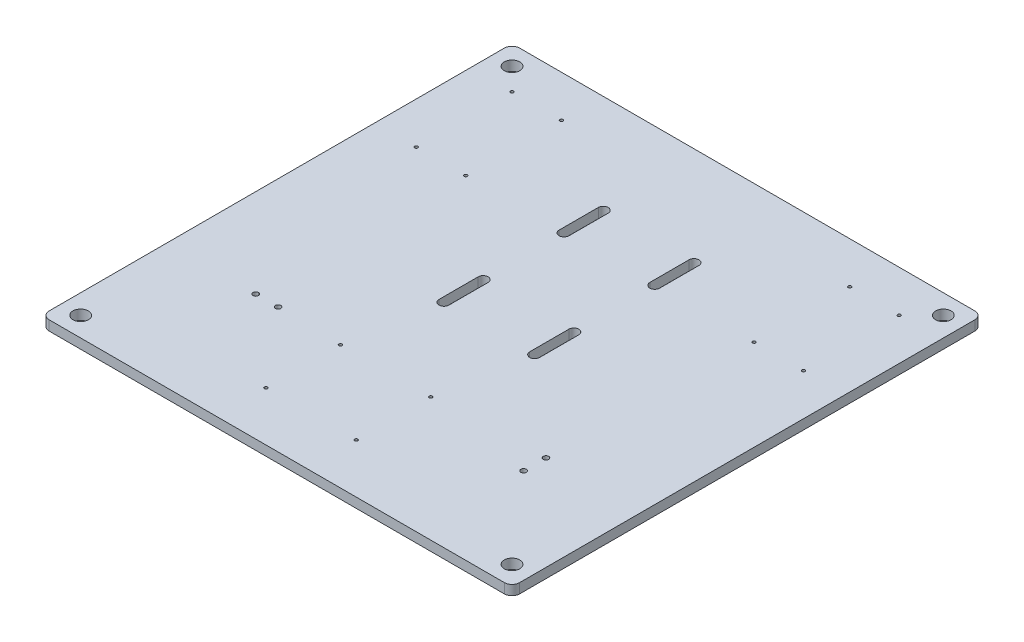
from build123d import *

# Parameters (mm, degrees)
SKETCH2_W           = 304.8
SKETCH2_H           = 304.8
SKETCH2_R           = 1
SKETCH2_R_2         = 1.75
SKETCH2_R_3         = 5
SKETCH2_R_4         = 1.016
BOSS_EXTRUDE1_DEPTH = 6.35
FILLET1_R           = 5
FILLET2_R           = 5
FILLET3_R           = 5
FILLET4_R           = 5


with BuildPart() as part:
    # Sketch2 → Boss-Extrude1 (new body)
    with BuildSketch(Plane(origin=(0, 0, 0), x_dir=(1, 0, 0), z_dir=(0, 1, 0))):
        with Locations((24.008323043, 69.071116712)):
            Rectangle(SKETCH2_W, SKETCH2_H)
        with Locations((-101.391676957, 132.471116712)):
            Circle(SKETCH2_R, mode=Mode.SUBTRACT)
        with Locations((-69.391676957, 132.471116712)):
            Circle(SKETCH2_R, mode=Mode.SUBTRACT)
        with Locations((-101.391676957, 194.471116712)):
            Circle(SKETCH2_R, mode=Mode.SUBTRACT)
        with Locations((-69.391676957, 194.471116712)):
            Circle(SKETCH2_R, mode=Mode.SUBTRACT)
        with Locations((149.408323043, 132.471116712)):
            Circle(SKETCH2_R, mode=Mode.SUBTRACT)
        with Locations((117.408323043, 132.471116712)):
            Circle(SKETCH2_R, mode=Mode.SUBTRACT)
        with Locations((117.408323043, 194.471116712)):
            Circle(SKETCH2_R, mode=Mode.SUBTRACT)
        with Locations((149.408323043, 194.471116712)):
            Circle(SKETCH2_R, mode=Mode.SUBTRACT)
        with Locations((114.958323043, 0.121116712)):
            Circle(SKETCH2_R_2, mode=Mode.SUBTRACT)
        with Locations((114.958323043, -14.378883288)):
            Circle(SKETCH2_R_2, mode=Mode.SUBTRACT)
        with Locations((-70.941676957, -1.996483288)):
            Circle(SKETCH2_R_2, mode=Mode.SUBTRACT)
        with Locations((-56.441676957, -1.996483288)):
            Circle(SKETCH2_R_2, mode=Mode.SUBTRACT)
        with Locations((163.708323043, 208.771116712)):
            Circle(SKETCH2_R_3, mode=Mode.SUBTRACT)
        with Locations((-115.691676957, 208.771116712)):
            Circle(SKETCH2_R_3, mode=Mode.SUBTRACT)
        with Locations((163.708323043, -70.628883288)):
            Circle(SKETCH2_R_3, mode=Mode.SUBTRACT)
        with Locations((-115.691676957, -70.628883288)):
            Circle(SKETCH2_R_3, mode=Mode.SUBTRACT)
        with Locations((43.439323043, -3.064883288)):
            Circle(SKETCH2_R_4, mode=Mode.SUBTRACT)
        with Locations((43.439323043, -51.324883288)):
            Circle(SKETCH2_R_4, mode=Mode.SUBTRACT)
        with Locations((-14.980676957, -3.064883288)):
            Circle(SKETCH2_R_4, mode=Mode.SUBTRACT)
        with Locations((-14.980676957, -51.324883288)):
            Circle(SKETCH2_R_4, mode=Mode.SUBTRACT)
        with BuildLine():
            Line((56.583323043, 54.371116712), (56.583323043, 79.771116712))
            ThreePointArc((56.583323043, 79.771116712), (53.383323043, 82.971116712), (50.183323043, 79.771116712))
            Line((50.183323043, 79.771116712), (50.183323043, 54.371116712))
            ThreePointArc((50.183323043, 54.371116712), (53.383323043, 51.171116712), (56.583323043, 54.371116712))
        make_face(mode=Mode.SUBTRACT)
        with BuildLine():
            Line((56.583323043, 157.571116712), (56.583323043, 132.171116712))
            ThreePointArc((56.583323043, 132.171116712), (53.383323043, 128.971116712), (50.183323043, 132.171116712))
            Line((50.183323043, 132.171116712), (50.183323043, 157.571116712))
            ThreePointArc((50.183323043, 157.571116712), (53.383323043, 160.771116712), (56.583323043, 157.571116712))
        make_face(mode=Mode.SUBTRACT)
        with BuildLine():
            Line((-8.566676957, 157.571116712), (-8.566676957, 132.171116712))
            ThreePointArc((-8.566676957, 132.171116712), (-5.366676957, 128.971116712), (-2.166676957, 132.171116712))
            Line((-2.166676957, 132.171116712), (-2.166676957, 157.571116712))
            ThreePointArc((-2.166676957, 157.571116712), (-5.366676957, 160.771116712), (-8.566676957, 157.571116712))
        make_face(mode=Mode.SUBTRACT)
        with BuildLine():
            Line((-8.566676957, 54.371116712), (-8.566676957, 79.771116712))
            ThreePointArc((-8.566676957, 79.771116712), (-5.366676957, 82.971116712), (-2.166676957, 79.771116712))
            Line((-2.166676957, 79.771116712), (-2.166676957, 54.371116712))
            ThreePointArc((-2.166676957, 54.371116712), (-5.366676957, 51.171116712), (-8.566676957, 54.371116712))
        make_face(mode=Mode.SUBTRACT)
    extrude(amount=BOSS_EXTRUDE1_DEPTH)

    # Fillet1
    fillet1_edges = [part.edges().sort_by_distance(p)[0] for p in [
        (176.408323043, 3.175, -221.471116712),
    ]]
    fillet(fillet1_edges, radius=FILLET1_R)

    # Fillet2
    fillet2_edges = [part.edges().sort_by_distance(p)[0] for p in [
        (-128.391676957, 3.175, -221.471116712),
    ]]
    fillet(fillet2_edges, radius=FILLET2_R)

    # Fillet3
    fillet3_edges = [part.edges().sort_by_distance(p)[0] for p in [
        (-128.391676957, 3.175, 83.328883288),
    ]]
    fillet(fillet3_edges, radius=FILLET3_R)

    # Fillet4
    fillet4_edges = [part.edges().sort_by_distance(p)[0] for p in [
        (176.408323043, 3.175, 83.328883288),
    ]]
    fillet(fillet4_edges, radius=FILLET4_R)


solid = part.part
